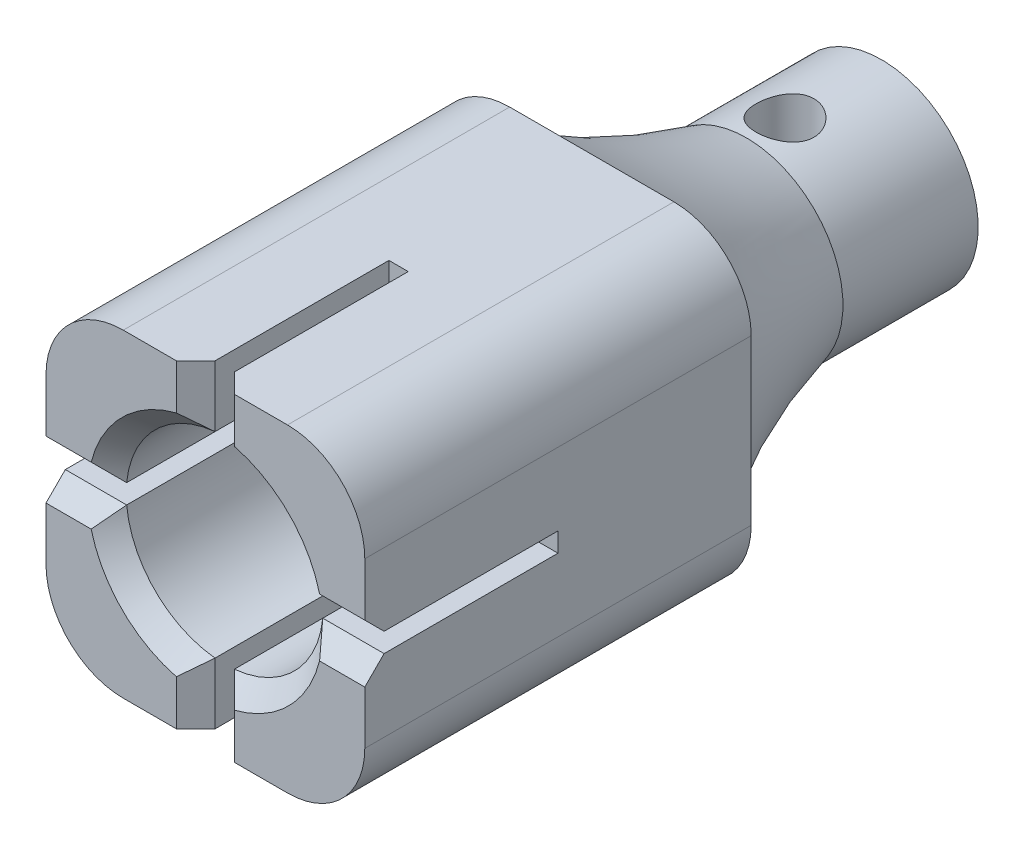
from build123d import *

# Parameters (mm, degrees)
BOSS_EXTRUDE1_DEPTH = 10
SKETCH12_R          = 5
BOSS_EXTRUDE3_DEPTH = 15
CUT_EXTRUDE3_DEPTH  = 40
SKETCH14_R          = 1.5
CUT_EXTRUDE4_DEPTH  = 12
CHAMFER5_SIZE       = 1
SKETCH10_W          = 1
SKETCH10_H          = 10
SKETCH10_W_2        = 10
SKETCH10_H_2        = 1
CUT_EXTRUDE5_DEPTH  = 25
SKETCH16_R          = 5.1
CUT_EXTRUDE6_DEPTH  = 25
CHAMFER6_SIZE       = 1
CHAMFER7_SIZE       = 1


with BuildPart() as part:
    # Sketch2 → Boss-Extrude1 (new body, symmetric)
    with BuildSketch(Plane.XY):
        with BuildLine():
            Line((4.25, -8.25), (-4.25, -8.25))
            ThreePointArc((-4.25, -8.25), (-7.078427125, -7.078427125), (-8.25, -4.25))
            Line((-8.25, -4.25), (-8.25, 4.25))
            ThreePointArc((-8.25, 4.25), (-7.078427125, 7.078427125), (-4.25, 8.25))
            Line((-4.25, 8.25), (4.25, 8.25))
            ThreePointArc((4.25, 8.25), (7.078427125, 7.078427125), (8.25, 4.25))
            Line((8.25, 4.25), (8.25, -4.25))
            ThreePointArc((8.25, -4.25), (7.078427125, -7.078427125), (4.25, -8.25))
        make_face()
    extrude(amount=BOSS_EXTRUDE1_DEPTH, both=True)

    # Sketch12 → Boss-Extrude3 (add)
    with BuildSketch(Plane(origin=(0, 0, -10), x_dir=(-1, 0, 0), z_dir=(0, 0, -1))):
        Circle(SKETCH12_R)
    extrude(amount=BOSS_EXTRUDE3_DEPTH)

    # Sketch13 → Cut-Extrude3 (cut)
    with BuildSketch(Plane(origin=(0, 0, -25), x_dir=(-1, 0, 0), z_dir=(0, 0, -1))):
        with BuildLine():
            Line((-2.076655966, 2.5), (2.076655966, 2.5))
            ThreePointArc((2.076655966, 2.5), (0, -3.25), (-2.076655966, 2.5))
        make_face()
    extrude(amount=-CUT_EXTRUDE3_DEPTH, mode=Mode.SUBTRACT)

    # Sketch14 → Cut-Extrude4 (cut)
    with BuildSketch(Plane(origin=(0, 0, 0), x_dir=(1, 0, 0), z_dir=(0, 1, 0))):
        with Locations((0, 20)):
            Circle(SKETCH14_R)
    extrude(amount=CUT_EXTRUDE4_DEPTH, mode=Mode.SUBTRACT)

    # Chamfer5
    chamfer5_edges = [part.edges().sort_by_distance(p)[0] for p in [
        (0, 2.5, -25),
        (0, -3.25, -25),
    ]]
    chamfer(chamfer5_edges, length=CHAMFER5_SIZE)

    # Sketch10 → Cut-Extrude5 (cut)
    with BuildSketch(Plane.XY):
        with Locations((0, 8)):
            Rectangle(SKETCH10_W, SKETCH10_H)
        with Locations((8, 0)):
            Rectangle(SKETCH10_W_2, SKETCH10_H_2)
        with Locations((0, -8)):
            Rectangle(SKETCH10_W, SKETCH10_H)
        with Locations((-8, 0)):
            Rectangle(SKETCH10_W_2, SKETCH10_H_2)
    extrude(amount=CUT_EXTRUDE5_DEPTH, mode=Mode.SUBTRACT)

    # Sketch16 → Cut-Extrude6 (cut)
    with BuildSketch(Plane.XY):
        Circle(SKETCH16_R)
    extrude(amount=CUT_EXTRUDE6_DEPTH, mode=Mode.SUBTRACT)

    # Sketch56 → Revolve3 (revolve)
    with BuildSketch(Plane(origin=(0, 0, 0), x_dir=(0, 0, -1), z_dir=(1, 0, 0))):
        with BuildLine():
            Line((10, 5), (10, 8.25))
            ThreePointArc((10, 8.25), (13.882456458, 6.335662049), (18, 5))
            Line((18, 5), (10, 5))
        make_face()
    revolve(axis=Axis((0, 0, 0), (0, 0, -1)))

    # Chamfer6
    chamfer6_edges = [part.edges().sort_by_distance(p)[0] for p in [
        (-3.606244584, -3.606244584, 10),
        (3.606244584, -3.606244584, 10),
        (3.606244584, 3.606244584, 10),
        (-3.606244584, 3.606244584, 10),
    ]]
    chamfer(chamfer6_edges, length=CHAMFER6_SIZE)

    # Chamfer7
    chamfer7_edges = [part.edges().sort_by_distance(p)[0] for p in [
        (0.5, 7.164736831, 10),
        (-0.5, 7.164736831, 10),
        (-7.164736831, 0.5, 10),
        (-7.164736831, -0.5, 10),
        (-0.5, -7.164736831, 10),
        (0.5, -7.164736831, 10),
        (7.164736831, -0.5, 10),
        (7.164736831, 0.5, 10),
    ]]
    chamfer(chamfer7_edges, length=CHAMFER7_SIZE)


solid = part.part
